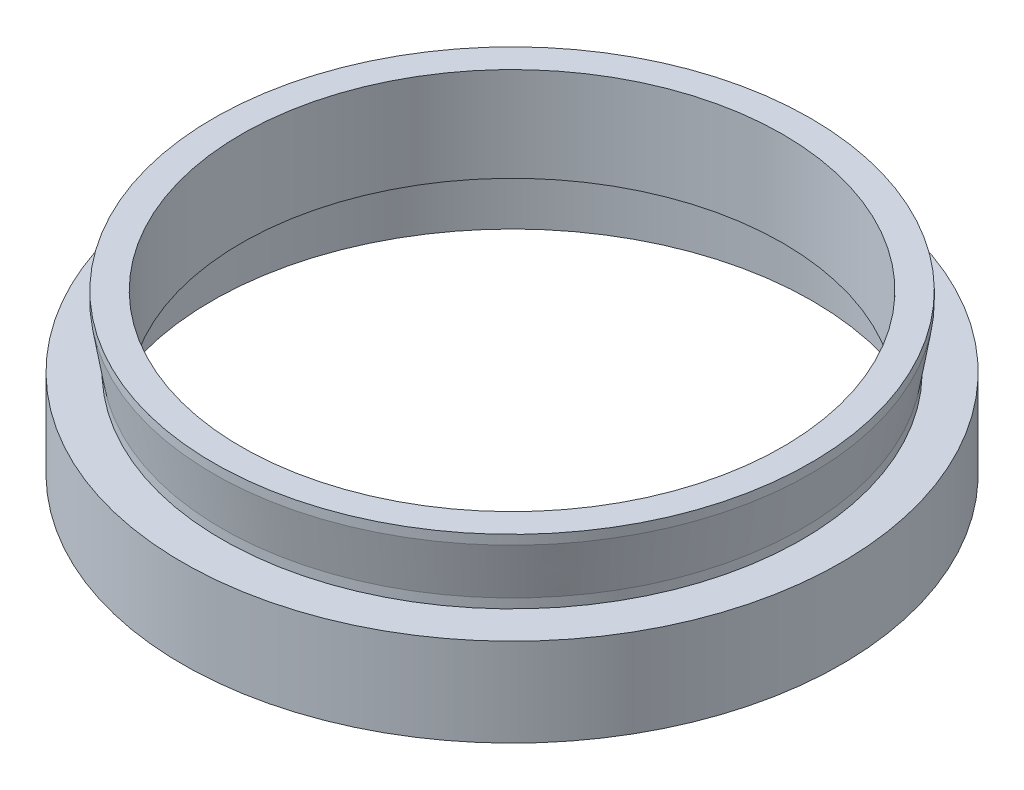
from build123d import *


with BuildPart() as part:
    # 草图1 → 旋转1 (revolve)
    with BuildSketch(Plane.XY, mode=Mode.PRIVATE) as revolve_1_sk:
        Polygon((-23, 5), (-23, 13), (-25.365, 13), (-25.365, 12.2), (-24.635, 7.8), (-24.635, 7), (-28, 7), (-28, -0.5), (-25.5, -0.5), (-25.5, 4), (-26.5, 4), (-26.5, 5), align=None)
    revolve(revolve_1_sk.sketch.rotate(Axis((0, 0, 0), (0, 1, 0)), 270), axis=Axis((0, 0, 0), (0, 1, 0)))  # turned: the seam where the file's is


solid = part.part
